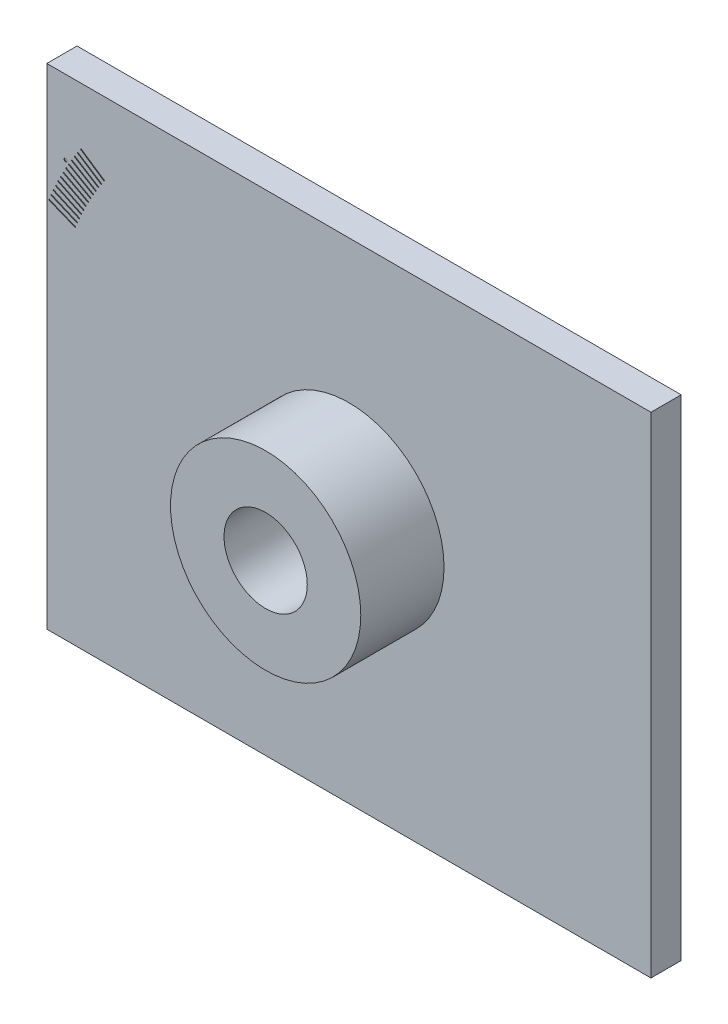
from build123d import *

# Parameters (mm, degrees)
SKETCH1_W         = 254
SKETCH1_H         = 206
BODY_DEPTH        = 12.7
SKETCH2_R         = 40
SPIGOT_DEPTH      = 35
SKETCH3_R         = 17.5
HOLE_DEPTH        = 48.7
SLIT_DEPTH        = 0.25
RIGHT_SLITS_COUNT = 5
RIGHT_SLITS_ANGLE = 4
LEFT_SLITS_COUNT  = 9
LEFT_SLITS_ANGLE  = 8
SKETCH7_R         = 0.65
TINY_HOLE_DEPTH   = 0.25


with BuildPart() as part:
    # Sketch1 → Body (new body)
    with BuildSketch(Plane.XY):
        with Locations((0, -3)):
            Rectangle(SKETCH1_W, SKETCH1_H)
    extrude(amount=BODY_DEPTH)

    # Sketch2 → Spigot (add)
    with BuildSketch(Plane.XY.offset(12.7)):
        Circle(SKETCH2_R)
    extrude(amount=SPIGOT_DEPTH)

    # Sketch3 → Hole (cut, through all)
    with BuildSketch(Plane.XY.offset(47.7)):
        Circle(SKETCH3_R)
    extrude(amount=-HOLE_DEPTH, mode=Mode.SUBTRACT)

    # Sketch4 → Slit (cut)
    with BuildSketch(Plane.XY.offset(12.7)):
        Polygon((-117.654454915, 68.216506351), (-107.262150069, 62.216506351), (-107.512150069, 61.783493649), (-117.904454915, 67.783493649), align=None)
    slit = extrude(amount=-SLIT_DEPTH, mode=Mode.SUBTRACT)

    # Right Slits: Slit ×5 about axis
    right_slits_axis = Axis((0, 0, 0), (0, 0, -1))
    for i in range(1, RIGHT_SLITS_COUNT):
        add(slit.rotate(right_slits_axis, i * RIGHT_SLITS_ANGLE / (RIGHT_SLITS_COUNT - 1)), mode=Mode.SUBTRACT)

    # Left Slits: Slit ×9 about axis
    left_slits_axis = Axis((0, 0, 0), (0, 0, 1))
    for i in range(1, LEFT_SLITS_COUNT):
        add(slit.rotate(left_slits_axis, i * LEFT_SLITS_ANGLE / (LEFT_SLITS_COUNT - 1)), mode=Mode.SUBTRACT)

    # Sketch7 → Tiny Hole (cut)
    with BuildSketch(Plane.XY.offset(12.7)):
        with Locations((-119.07849302, 68.75)):
            Circle(SKETCH7_R)
    extrude(amount=-TINY_HOLE_DEPTH, mode=Mode.SUBTRACT)


solid = part.part
